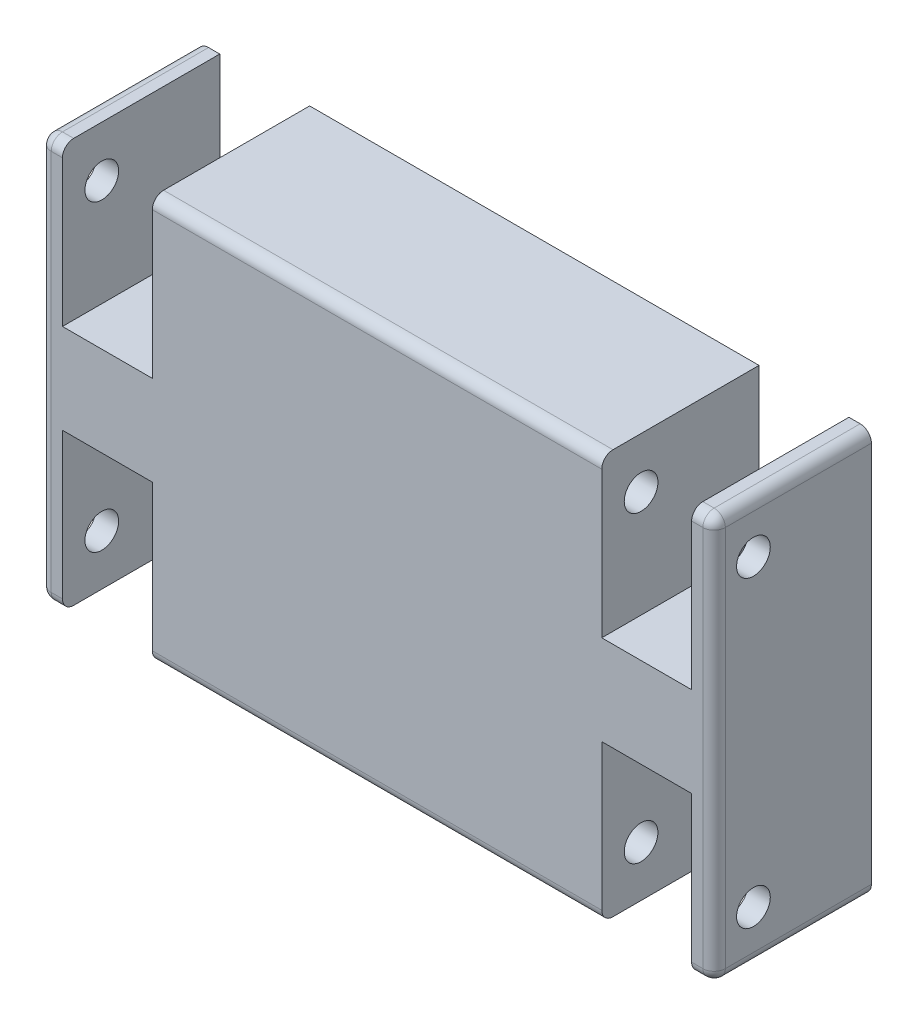
from build123d import *

# Parameters (mm, degrees)
CROQUIS2_W              = 300
CROQUIS2_H              = 180
SALIENTE_EXTRUIR3_DEPTH = 70
CROQUIS3_W              = 40
CROQUIS3_H              = 70
CORTAR_EXTRUIR1_DEPTH   = 70
CROQUIS4_R              = 7.5
CORTAR_EXTRUIR2_DEPTH   = 400
REDONDEO2_R             = 5
REDONDEO3_R             = 5
REDONDEO4_R             = 5
REDONDEO5_R             = 5
REDONDEO6_R             = 5
REDONDEO7_R             = 5
REDONDEO8_R             = 5
REDONDEO9_R             = 5


with BuildPart() as part:
    # Croquis2 → Saliente-Extruir3 (new body)
    with BuildSketch(Plane.XY):
        with Locations((150, 90)):
            Rectangle(CROQUIS2_W, CROQUIS2_H)
    extrude(amount=SALIENTE_EXTRUIR3_DEPTH)

    # Croquis3 → Cortar-Extruir1 (cut)
    with BuildSketch(Plane.XY.offset(70)):
        with Locations((30, 145)):
            Rectangle(CROQUIS3_W, CROQUIS3_H)
        with Locations((270, 35)):
            Rectangle(CROQUIS3_W, CROQUIS3_H)
        with Locations((30, 35)):
            Rectangle(CROQUIS3_W, CROQUIS3_H)
        with Locations((270, 145)):
            Rectangle(CROQUIS3_W, CROQUIS3_H)
    extrude(amount=-CORTAR_EXTRUIR1_DEPTH, mode=Mode.SUBTRACT)

    # Croquis4 → Cortar-Extruir2 (cut)
    with BuildSketch(Plane(origin=(300, 0, 0), x_dir=(0, 0, -1), z_dir=(1, 0, 0))):
        with Locations((-52.5, 157.5)):
            Circle(CROQUIS4_R)
        with Locations((-52.5, 22.5)):
            Circle(CROQUIS4_R)
    extrude(amount=-CORTAR_EXTRUIR2_DEPTH, mode=Mode.SUBTRACT)

    # Redondeo2
    redondeo2_edges = [part.edges().sort_by_distance(p)[0] for p in [
        (150, 0, 70),
    ]]
    fillet(redondeo2_edges, radius=REDONDEO2_R)

    # Redondeo3
    redondeo3_edges = [part.edges().sort_by_distance(p)[0] for p in [
        (150, 180, 70),
    ]]
    fillet(redondeo3_edges, radius=REDONDEO3_R)

    # Redondeo4
    redondeo4_edges = [part.edges().sort_by_distance(p)[0] for p in [
        (5, 180, 70),
    ]]
    fillet(redondeo4_edges, radius=REDONDEO4_R)

    # Redondeo5
    redondeo5_edges = [part.edges().sort_by_distance(p)[0] for p in [
        (295, 180, 70),
    ]]
    fillet(redondeo5_edges, radius=REDONDEO5_R)

    # Redondeo6
    redondeo6_edges = [part.edges().sort_by_distance(p)[0] for p in [
        (295, 0, 70),
    ]]
    fillet(redondeo6_edges, radius=REDONDEO6_R)

    # Redondeo7
    redondeo7_edges = [part.edges().sort_by_distance(p)[0] for p in [
        (5, 0, 70),
    ]]
    fillet(redondeo7_edges, radius=REDONDEO7_R)

    # Redondeo8
    redondeo8_edges = [part.edges().sort_by_distance(p)[0] for p in [
        (0, 90, 70),
        (0, 180, 32.5),
        (0, 0, 32.5),
    ]]
    fillet(redondeo8_edges, radius=REDONDEO8_R)

    # Redondeo9
    redondeo9_edges = [part.edges().sort_by_distance(p)[0] for p in [
        (300, 180, 32.5),
        (300, 90, 70),
        (300, 0, 32.5),
    ]]
    fillet(redondeo9_edges, radius=REDONDEO9_R)


solid = part.part
